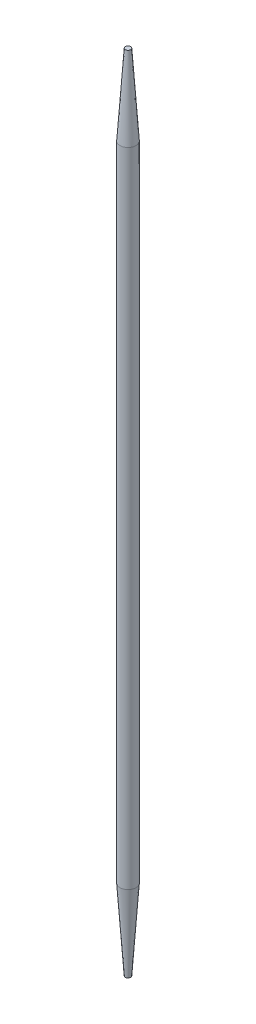
from build123d import *

# Parameters (mm, degrees)
ESQUISSE1_R             = 1.5
BOSS_EXTRU_1_DEPTH      = 150
CHANFREIN1_SIZE         = 1
CHANFREIN1_SIZE2        = 15
CHANFREIN1_PART_2_SIZE  = 1
CHANFREIN1_PART_2_SIZE2 = 15


with BuildPart() as part:
    # Esquisse1 → Boss.-Extru.1 (new body)
    with BuildSketch(Plane(origin=(0, 0, 0), x_dir=(1, 0, 0), z_dir=(0, 1, 0))):
        Circle(ESQUISSE1_R)
    extrude(amount=BOSS_EXTRU_1_DEPTH)

    # Chanfrein1
    chanfrein1_edges = [part.edges().sort_by_distance(p)[0] for p in [
        (-1.5, 0, 0),
    ]]
    chanfrein1_side = [part.faces().sort_by_distance(p)[0] for p in [
        (0, 0, 0),
    ]]
    chamfer(chanfrein1_edges, length=CHANFREIN1_SIZE, length2=CHANFREIN1_SIZE2, reference=chanfrein1_side[0])

    # Chanfrein1 part 2
    chanfrein1_part_2_edges = [part.edges().sort_by_distance(p)[0] for p in [
        (-1.5, 150, 0),
    ]]
    chanfrein1_part_2_side = [part.faces().sort_by_distance(p)[0] for p in [
        (0, 150, 0),
    ]]
    chamfer(chanfrein1_part_2_edges, length=CHANFREIN1_PART_2_SIZE, length2=CHANFREIN1_PART_2_SIZE2, reference=chanfrein1_part_2_side[0])


solid = part.part
